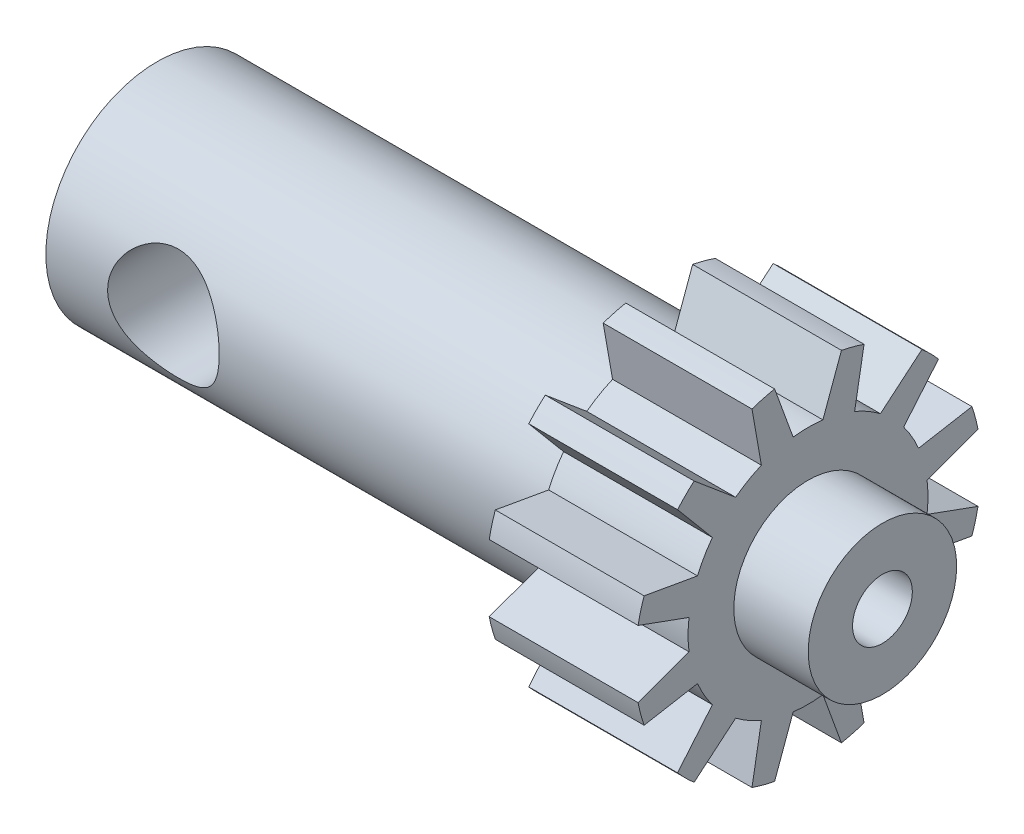
from build123d import *

# Parameters (mm, degrees)
HOLE1_D                     = 9.525
F_1_4_20_TAPPED_HOLE1_D     = 5.1054
F_1_4_20_TAPPED_HOLE1_DEPTH = 16.51
F_1_4_20_TAPPED_HOLE1_TIP   = 1.533816902
CUT_EXTRUDE1_START          = -56.5498001
CUT_EXTRUDE1_DEPTH          = 63.8998001
CIRPATTERN1_COUNT           = 12


with BuildPart() as part:
    # Sketch1 → Revolve1 (revolve)
    with BuildSketch(Plane.XY):
        Polygon((0, 0), (0, 9.49325), (42.8498, 9.49325), (42.8498, 14.7828), (55.5498, 14.7828), (55.5498, 6.33476), (61.8998, 6.33476), (61.8998, 0), align=None)
    revolve(axis=Axis((0, 0, 0), (-1, 0, 0)))

    # Hole1 (through all)
    with Locations(Plane(origin=(10.033, 0, 9.49325), x_dir=(0, 1, 0), z_dir=(0, 0, 1))):
        with Locations((0, 0)):
            Hole(HOLE1_D / 2)

    # 1/4-20 Tapped Hole1
    with Locations(Plane(origin=(61.8998, 0, 0), x_dir=(0, 0, -1), z_dir=(1, 0, 0))):
        with Locations((0, 0)):
            Hole(F_1_4_20_TAPPED_HOLE1_D / 2, depth=F_1_4_20_TAPPED_HOLE1_DEPTH)
            with Locations((0, 0, -(F_1_4_20_TAPPED_HOLE1_DEPTH + F_1_4_20_TAPPED_HOLE1_TIP / 2))):  # 118° drill point
                Cone(0, F_1_4_20_TAPPED_HOLE1_D / 2, F_1_4_20_TAPPED_HOLE1_TIP, mode=Mode.SUBTRACT)

    # Sketch13 → Cut-Extrude1 (cut)
    with BuildSketch(Plane(origin=(55.5498, 0, 0), x_dir=(0, 0, -1), z_dir=(1, 0, 0)).offset(CUT_EXTRUDE1_START)):
        with BuildLine():
            Line((-2.852495169, 14.504980081), (-1.27, 10.157110339))
            ThreePointArc((-1.27, 10.157110339), (0, 10.2362), (1.27, 10.157110339))
            Line((1.27, 10.157110339), (2.852495169, 14.504980081))
            ThreePointArc((2.852495169, 14.504980081), (0, 14.7828), (-2.852495169, 14.504980081))
        make_face()
    cut_extrude1 = extrude(amount=CUT_EXTRUDE1_DEPTH, mode=Mode.SUBTRACT)

    # CirPattern1: Cut-Extrude1 ×12 about axis
    cirpattern1_axis = Axis((55.5498, 0, 0), (1, 0, 0))
    for i in range(1, CIRPATTERN1_COUNT):
        add(cut_extrude1.rotate(cirpattern1_axis, i * 360 / CIRPATTERN1_COUNT), mode=Mode.SUBTRACT)


solid = part.part
